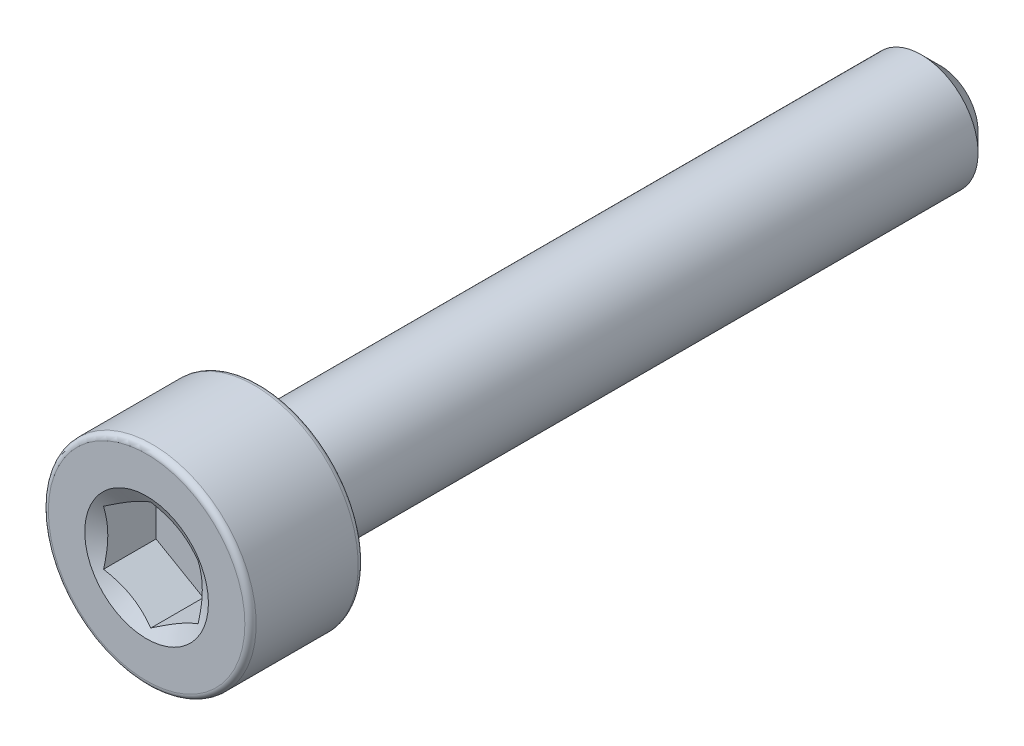
from build123d import *

# Parameters (mm, degrees)
CUT_EXTRUDE1_START = 10.5
CUT_EXTRUDE1_DEPTH = 1.5


with BuildPart() as part:
    # Sketch2 → Revolve1 (revolve)
    with BuildSketch(Plane(origin=(0, 0, 0), x_dir=(0, 0, -1), z_dir=(1, 0, 0)), mode=Mode.PRIVATE) as revolve1_sk:
        with BuildLine():
            Line((10.5, 0), (10.5, 1))
            Line((10.5, 1), (10, 1.5))
            Line((10, 1.5), (-7.5, 1.5))
            Line((-7.5, 1.5), (-7.5, 2.6))
            ThreePointArc((-7.5, 2.6), (-7.543933983, 2.706066017), (-7.65, 2.75))
            Line((-7.65, 2.75), (-10.35, 2.75))
            ThreePointArc((-10.35, 2.75), (-10.456066017, 2.706066017), (-10.5, 2.6))
            Line((-10.5, 2.6), (-10.5, 0))
            Line((-10.5, 0), (10.5, 0))
        make_face()
    revolve(revolve1_sk.sketch.rotate(Axis((0, 0, -10.5), (0, 0, 1)), 90), axis=Axis((0, 0, -10.5), (0, 0, 1)))

    # Sketch3 → Cut-Extrude1 (cut)
    with BuildSketch(Plane.XY.offset(CUT_EXTRUDE1_START)):
        Polygon((-1.25, 0.721687836), (-1.25, -0.721687836), (0, -1.443375673), (1.25, -0.721687836), (1.25, 0.721687836), (0, 1.443375673), align=None)
    extrude(amount=-CUT_EXTRUDE1_DEPTH, mode=Mode.SUBTRACT)

    # Cut-Extrude2 cone 1 section (through the dimple's axis) → Cut-Extrude2 (revolve, cut)
    with BuildSketch(Plane(origin=(0, 0, 10.5), x_dir=(0, -1, 0), z_dir=(1, 0, 0))):
        Polygon((0, 0), (1.636146394, 0), (0, 0.944629561), align=None)
    revolve(axis=Axis((0, 0, 10.5), (0, 0, -1)), mode=Mode.SUBTRACT)


solid = part.part
